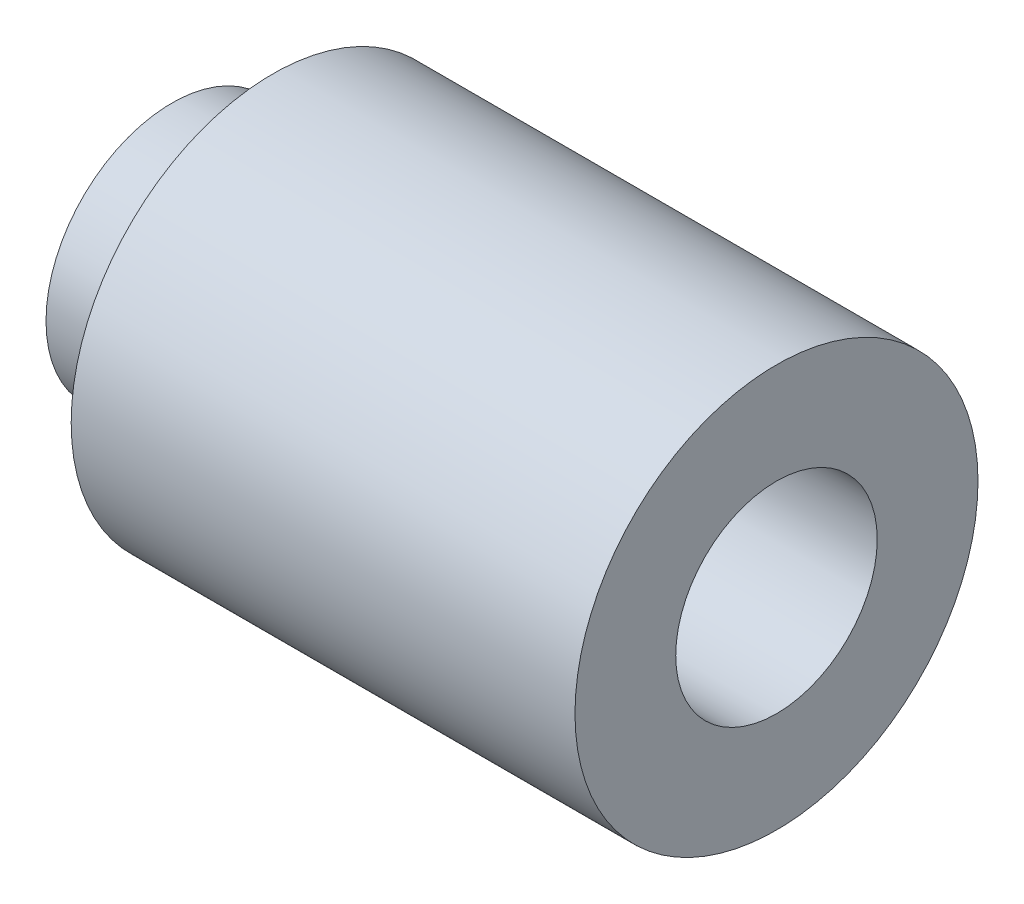
from build123d import *

# Parameters (mm, degrees)
SKETCH1_R           = 4
SKETCH1_R_2         = 2
BOSS_EXTRUDE1_DEPTH = 10
SKETCH2_R           = 2.5
SKETCH2_R_2         = 2
BOSS_EXTRUDE2_DEPTH = 2


with BuildPart() as part:
    # Sketch1 → Boss-Extrude1 (new body)
    with BuildSketch(Plane(origin=(0, 0, 0), x_dir=(0, 0, -1), z_dir=(1, 0, 0))):
        Circle(SKETCH1_R)
        Circle(SKETCH1_R_2, mode=Mode.SUBTRACT)
    extrude(amount=BOSS_EXTRUDE1_DEPTH)

    # Sketch2 → Boss-Extrude2 (add)
    with BuildSketch(Plane.ZY):
        Circle(SKETCH2_R)
        Circle(SKETCH2_R_2, mode=Mode.SUBTRACT)
    extrude(amount=BOSS_EXTRUDE2_DEPTH)


solid = part.part
